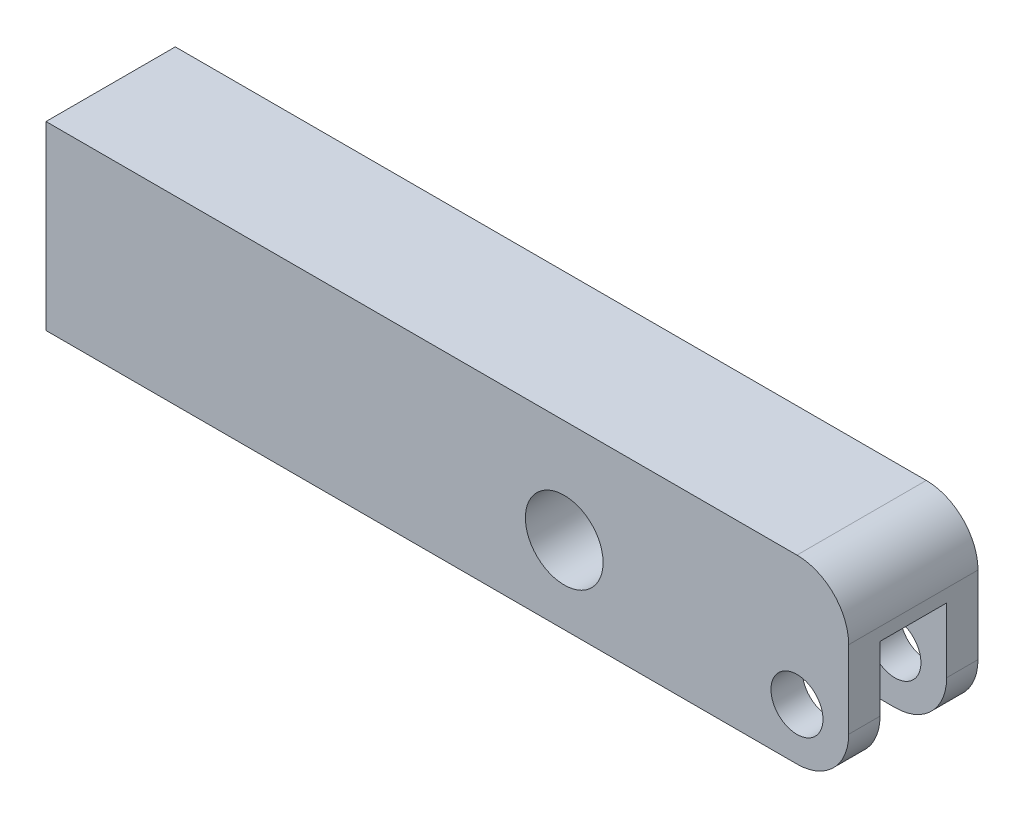
from build123d import *

# Parameters (mm, degrees)
SKETCH11_W         = 98.552
SKETCH11_H         = 22.225
SKETCH11_R         = 3.19405
SKETCH11_R_2       = 4.76885
EXTRUDE3_DEPTH     = 7.9375
CUT_EXTRUDE1_DEPTH = 14.3002
FILLET1_R          = 6.35


with BuildPart() as part:
    # Sketch11 → Extrude3 (new body, symmetric)
    with BuildSketch(Plane.XY):
        with Locations((-42.926, 4.7625)):
            Rectangle(SKETCH11_W, SKETCH11_H)
        Circle(SKETCH11_R, mode=Mode.SUBTRACT)
        with Locations((-28.575, 3.175)):
            Circle(SKETCH11_R_2, mode=Mode.SUBTRACT)
    extrude(amount=EXTRUDE3_DEPTH, both=True)

    # Sketch12 → Cut-Extrude1 (cut)
    with BuildSketch(Plane.XZ.offset(6.35)):
        with BuildLine():
            Line((-7.9248, 4.0894), (6.35, 4.0894))
            Line((6.35, 4.0894), (6.35, -4.0894))
            Line((6.35, -4.0894), (-7.9248, -4.0894))
            ThreePointArc((-7.9248, -4.0894), (-12.0142, 0), (-7.9248, 4.0894))
        make_face()
    extrude(amount=-CUT_EXTRUDE1_DEPTH, mode=Mode.SUBTRACT)

    # Fillet1
    fillet1_edges = [part.edges().sort_by_distance(p)[0] for p in [
        (6.35, -6.35, -6.01345),
        (6.35, 15.875, 0),
        (6.35, -6.35, 6.01345),
    ]]
    fillet(fillet1_edges, radius=FILLET1_R)


solid = part.part
